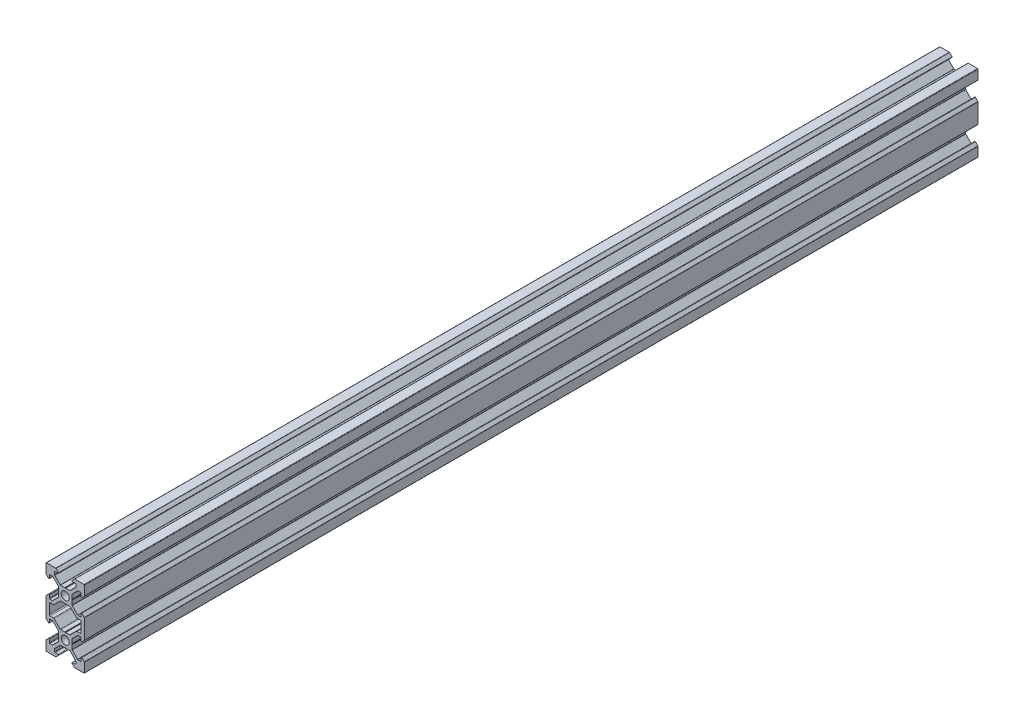
from build123d import *

# Parameters (mm, degrees)
SKETCH1_R           = 2.1
BOSS_EXTRUDE1_DEPTH = 465
FILLET1_R           = 0.25
FILLET2_R           = 0.5
CUT_EXTRUDE1_DEPTH  = 466


with BuildPart() as part:
    # Sketch1 → Boss-Extrude1 (new body)
    with BuildSketch(Plane.XY):
        Polygon((3.560660172, -2.5), (3.560660172, 2.5), (6.560660172, 5.5), (8.252142372, 5.5), (8.252142372, 3.1), (10, 4.847857628), (10, 10), (4.847857628, 10), (3.1, 8.252142372), (5.5, 8.252142372), (5.5, 6.560660172), (2.5, 3.560660172), (-2.5, 3.560660172), (-5.5, 6.560660172), (-5.5, 8.252142372), (-3.1, 8.252142372), (-4.847857628, 10), (-10, 10), (-10, 4.847857628), (-8.252142372, 3.1), (-8.252142372, 5.5), (-6.560660172, 5.5), (-3.560660172, 2.5), (-3.560660172, -2.5), (-6.560660172, -5.5), (-8.252142372, -5.5), (-8.252142372, -3.1), (-10, -4.847857628), (-10, -7), (-10, -13), (-10, -15.152142372), (-8.252142372, -16.9), (-8.252142372, -14.5), (-6.560660172, -14.5), (-3.560660172, -17.5), (-3.560660172, -22.5), (-6.560660172, -25.5), (-8.252142372, -25.5), (-8.252142372, -23.1), (-10, -24.847857628), (-10, -30), (-4.847857628, -30), (-3.1, -28.252142372), (-5.5, -28.252142372), (-5.5, -26.560660172), (-2.5, -23.560660172), (2.5, -23.560660172), (5.5, -26.560660172), (5.5, -28.252142372), (3.1, -28.252142372), (4.847857628, -30), (10, -30), (10, -24.847857628), (8.252142372, -23.1), (8.252142372, -25.5), (6.560660172, -25.5), (3.560660172, -22.5), (3.560660172, -17.5), (6.560660172, -14.5), (8.252142372, -14.5), (8.252142372, -16.9), (10, -15.152142372), (10, -13), (10, -7), (10, -4.847857628), (8.252142372, -3.1), (8.252142372, -5.5), (6.560660172, -5.5), align=None)
        Circle(SKETCH1_R, mode=Mode.SUBTRACT)
        with Locations((0, -20)):
            Circle(SKETCH1_R, mode=Mode.SUBTRACT)
        Polygon((2.5, -3.560660172), (-2.5, -3.560660172), (-5.5, -6.560660172), (-5.939339828, -7), (-8.252142372, -7), (-8.252142372, -13), (-5.939339828, -13), (-5.5, -13.439339828), (-2.5, -16.439339828), (2.5, -16.439339828), (5.5, -13.439339828), (5.939339828, -13), (8.252142372, -13), (8.252142372, -7), (5.939339828, -7), (5.5, -6.560660172), align=None, mode=Mode.SUBTRACT)
    extrude(amount=BOSS_EXTRUDE1_DEPTH)

    # Fillet1
    fillet1_edges = [part.edges().sort_by_distance(p)[0] for p in [
        (5.5, 6.560660172, 232.5),
        (5.5, 8.252142372, 232.5),
        (3.1, 8.252142372, 232.5),
        (4.847857628, 10, 232.5),
        (10, 10, 232.5),
        (10, 4.847857628, 232.5),
        (8.252142372, 3.1, 232.5),
        (8.252142372, 5.5, 232.5),
        (6.560660172, 5.5, 232.5),
        (3.560660172, 2.5, 232.5),
        (3.560660172, -2.5, 232.5),
        (6.560660172, -5.5, 232.5),
        (8.252142372, -5.5, 232.5),
        (8.252142372, -3.1, 232.5),
        (10, -4.847857628, 232.5),
        (10, -15.152142372, 232.5),
        (8.252142372, -16.9, 232.5),
        (8.252142372, -14.5, 232.5),
        (6.560660172, -14.5, 232.5),
        (3.560660172, -17.5, 232.5),
        (3.560660172, -22.5, 232.5),
        (6.560660172, -25.5, 232.5),
        (8.252142372, -25.5, 232.5),
        (8.252142372, -23.1, 232.5),
        (10, -24.847857628, 232.5),
        (10, -30, 232.5),
        (4.847857628, -30, 232.5),
        (3.1, -28.252142372, 232.5),
        (5.5, -28.252142372, 232.5),
        (5.5, -26.560660172, 232.5),
        (2.5, -23.560660172, 232.5),
        (-2.5, -23.560660172, 232.5),
        (-5.5, -26.560660172, 232.5),
        (-5.5, -28.252142372, 232.5),
        (-3.1, -28.252142372, 232.5),
        (-4.847857628, -30, 232.5),
        (-10, -30, 232.5),
        (-10, -24.847857628, 232.5),
        (-8.252142372, -23.1, 232.5),
        (-8.252142372, -25.5, 232.5),
        (-6.560660172, -25.5, 232.5),
        (-3.560660172, -22.5, 232.5),
        (-3.560660172, -17.5, 232.5),
        (-6.560660172, -14.5, 232.5),
        (-8.252142372, -14.5, 232.5),
        (-8.252142372, -16.9, 232.5),
        (-10, -15.152142372, 232.5),
        (-10, -4.847857628, 232.5),
        (-8.252142372, -3.1, 232.5),
        (-8.252142372, -5.5, 232.5),
        (-6.560660172, -5.5, 232.5),
        (-3.560660172, -2.5, 232.5),
        (-3.560660172, 2.5, 232.5),
        (-6.560660172, 5.5, 232.5),
        (-8.252142372, 5.5, 232.5),
        (-8.252142372, 3.1, 232.5),
        (-10, 4.847857628, 232.5),
        (-10, 10, 232.5),
        (-4.847857628, 10, 232.5),
        (-3.1, 8.252142372, 232.5),
        (-5.5, 8.252142372, 232.5),
        (-5.5, 6.560660172, 232.5),
        (-2.5, 3.560660172, 232.5),
        (2.5, 3.560660172, 232.5),
    ]]
    fillet(fillet1_edges, radius=FILLET1_R)

    # Fillet2
    fillet2_edges = [part.edges().sort_by_distance(p)[0] for p in [
        (-2.5, -3.560660172, 232.5),
        (-5.939339828, -7, 232.5),
        (-8.252142372, -7, 232.5),
        (-8.252142372, -13, 232.5),
        (-5.939339828, -13, 232.5),
        (-2.5, -16.439339828, 232.5),
        (2.5, -16.439339828, 232.5),
        (5.939339828, -13, 232.5),
        (8.252142372, -13, 232.5),
        (8.252142372, -7, 232.5),
        (5.939339828, -7, 232.5),
        (2.5, -3.560660172, 232.5),
    ]]
    fillet(fillet2_edges, radius=FILLET2_R)

    # Sketch2 → Cut-Extrude1 (cut, through all)
    with BuildSketch(Plane.XY.offset(465)):
        Polygon((0, 3.398953432), (-0.242280927, 3.560660172), (0.242280927, 3.560660172), align=None)
        Polygon((0, -3.398953432), (0.242280927, -3.560660172), (-0.242280927, -3.560660172), align=None)
        Polygon((3.560660172, 0.242280927), (3.560660172, -0.242280927), (3.398953432, 0), align=None)
        Polygon((-3.560660172, 0.242280927), (-3.560660172, -0.242280927), (-3.398953432, 0), align=None)
        Polygon((-3.398953432, -20), (-3.560660172, -20.242280927), (-3.560660172, -19.757719073), align=None)
        Polygon((3.398953432, -20), (3.560660172, -19.757719073), (3.560660172, -20.242280927), align=None)
        Polygon((-0.242280927, -16.439339828), (0.242280927, -16.439339828), (0, -16.601046568), align=None)
        Polygon((-0.242280927, -23.560660172), (0.242280927, -23.560660172), (0, -23.398953432), align=None)
    extrude(amount=-CUT_EXTRUDE1_DEPTH, mode=Mode.SUBTRACT)


solid = part.part
